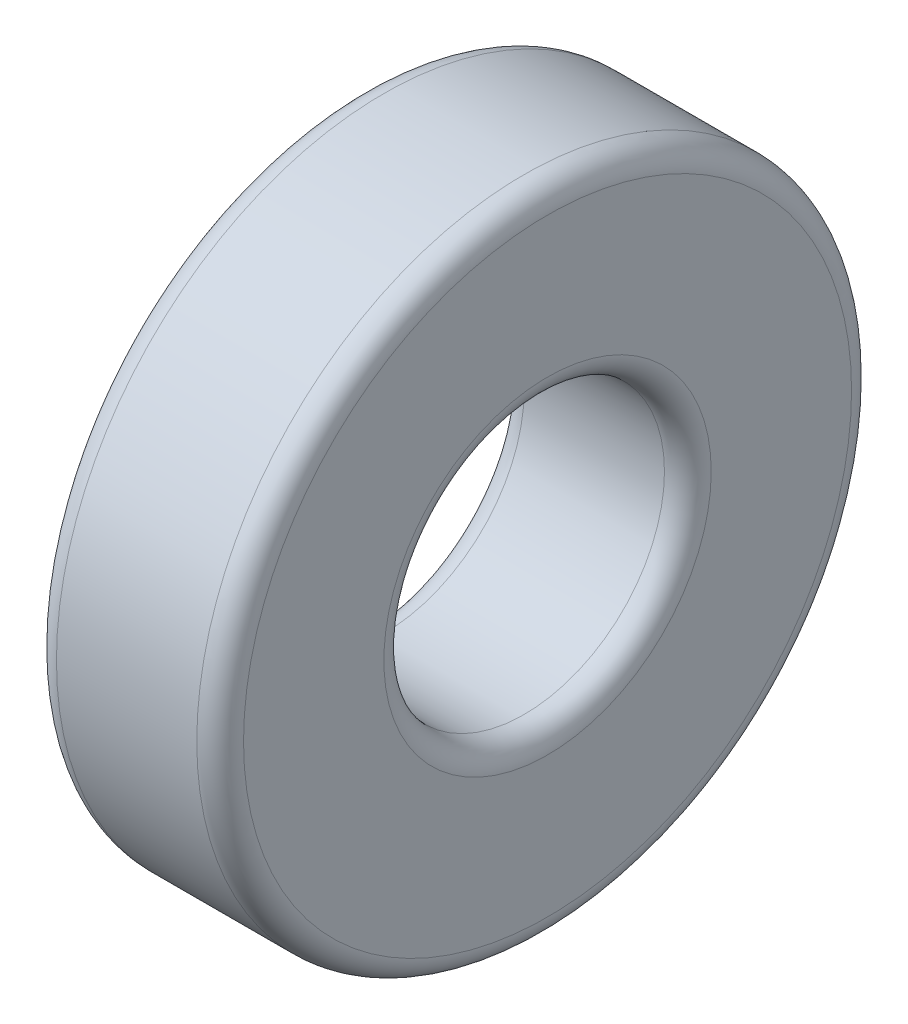
from build123d import *


with BuildPart() as part:
    # Эскиз1 → Повернуть1 (revolve)
    with BuildSketch(Plane.XY):
        with BuildLine():
            Line((0, 7), (0, 13))
            ThreePointArc((0, 13), (-0.292893219, 13.707106781), (-1, 14))
            Line((-1, 14), (-7, 14))
            ThreePointArc((-7, 14), (-7.707106781, 13.707106781), (-8, 13))
            Line((-8, 13), (-8, 7))
            ThreePointArc((-8, 7), (-7.707106781, 6.292893219), (-7, 6))
            Line((-7, 6), (-1, 6))
            ThreePointArc((-1, 6), (-0.292893219, 6.292893219), (0, 7))
        make_face()
    revolve(axis=Axis((0, 0, 0), (-1, 0, 0)))


solid = part.part
